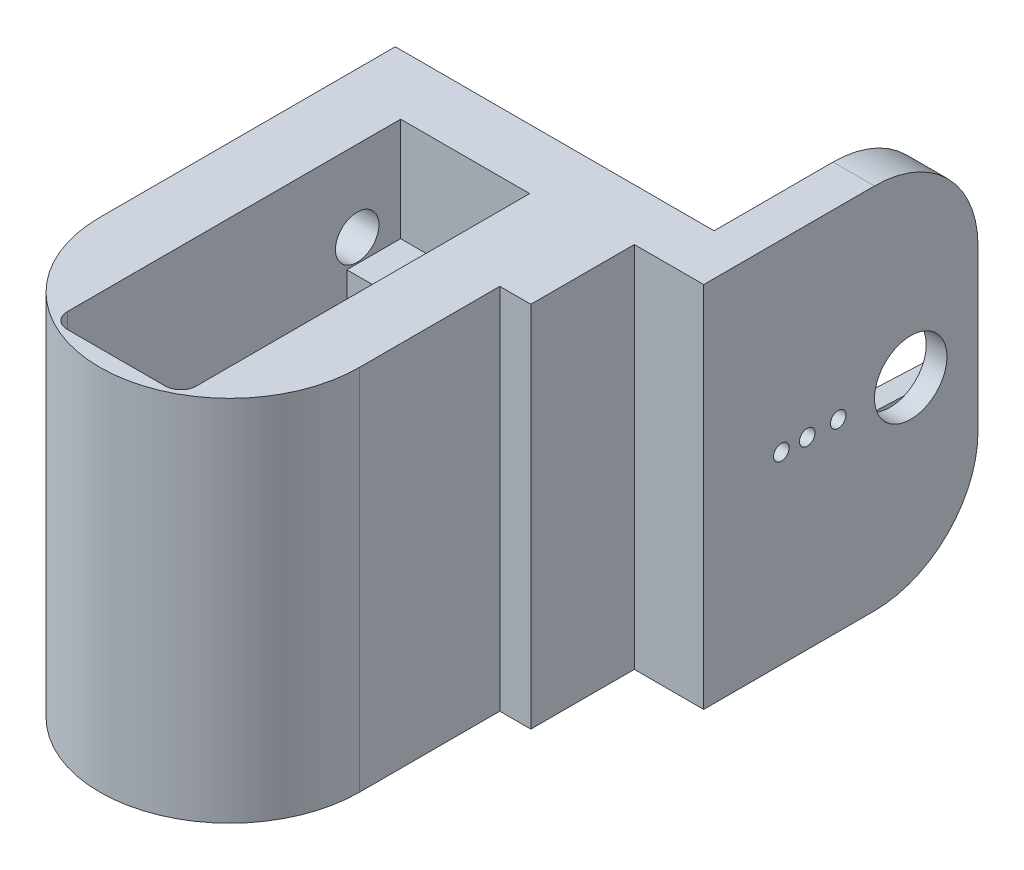
from build123d import *

# Parameters (mm, degrees)
SKETCH4_W                = 12.46
SKETCH4_H                = 17.25
BOSS_EXTRUDE3_DEPTH      = 6
SKETCH8_R                = 12.546781182
SKETCH8_R_2              = 11.15
BOSS_EXTRUDE6_DEPTH      = 8.3
BOSS_EXTRUDE6_DEPTH_BACK = 17.25
BOSS_EXTRUDE4_DEPTH      = 17.25
SKETCH6_R                = 0.75
CUT_EXTRUDE1_DEPTH       = 5
CHAMFER1_SIZE            = 0.5
CHAMFER1_SIZE2           = 0.866025404
SKETCH10_W               = 12.46
SKETCH10_H               = 23.7
CUT_EXTRUDE3_DEPTH       = 17.25
BOSS_EXTRUDE7_DEPTH      = 8.3
BOSS_EXTRUDE9_DEPTH      = 10
SKETCH20_R               = 11.15
SKETCH20_R_2             = 7.15
BOSS_EXTRUDE11_DEPTH     = 8.3
SKETCH21_R               = 10.15
SKETCH21_R_2             = 7.15
CUT_EXTRUDE7_DEPTH       = 1.3
SKETCH11_W               = 10
SKETCH11_H               = 2
CUT_EXTRUDE4_DEPTH       = 23.7
CUT_EXTRUDE8_REACH       = 37.55
SKETCH25_W               = 12.46
SKETCH25_H               = 6
BOSS_EXTRUDE10_DEPTH     = 35.55
SKETCH18_W               = 21.5
SKETCH18_H               = 11.438292938
CUT_EXTRUDE5_DEPTH       = 2
SKETCH19_R               = 3.5
CUT_EXTRUDE6_DEPTH       = 43.5
CUT_EXTRUDE6_DEPTH_BACK  = 3
FILLET1_R                = 10
SKETCH22_R               = 6.5
BOSS_EXTRUDE12_DEPTH     = 5
SKETCH23_R               = 5.85
BOSS_EXTRUDE13_DEPTH     = 5
FILLET2_R                = 1
BOSS_EXTRUDE14_DEPTH     = 2
CUT_EXTRUDE9_REACH       = 46.5
SKETCH27_R               = 0.75
CUT_EXTRUDE10_DEPTH      = 36.55
SKETCH29_R               = 2.1
SKETCH29_R_2             = 3.2
CUT_EXTRUDE11_DEPTH      = 7
FILLET3_R                = 1
SKETCH31_W               = 10
SKETCH31_H               = 35.55
BOSS_EXTRUDE15_DEPTH     = 3


with BuildPart() as part:
    # Sketch4 → Boss-Extrude3 (new body)
    with BuildSketch(Plane.XY):
        with Locations((0, -1.35)):
            Rectangle(SKETCH4_W, SKETCH4_H)
    extrude(amount=BOSS_EXTRUDE3_DEPTH)



with BuildPart() as body_2:
    # Sketch8 → Boss-Extrude6 (new body, two sides)
    with BuildSketch(Plane(origin=(0, -9.975, 0), x_dir=(-1, 0, 0), z_dir=(0, -1, 0))) as boss_extrude6_sk:
        with Locations((0, -23.55)):
            Circle(SKETCH8_R)
        with Locations((0, -23.55)):
            Circle(SKETCH8_R_2, mode=Mode.SUBTRACT)
    extrude(amount=BOSS_EXTRUDE6_DEPTH)
    extrude(boss_extrude6_sk.sketch, amount=-BOSS_EXTRUDE6_DEPTH_BACK)


with BuildPart() as part_1:
    add(part.part)

    add(body_2.part)  # Boss-Extrude4 merges body 2
    # Sketch5 → Boss-Extrude4 (add)
    with BuildSketch(Plane(origin=(0, 7.275, 0), x_dir=(1, 0, 0), z_dir=(0, 1, 0))):
        with BuildLine():
            Line((12.546781182, -23.55), (12.546781182, 0))
            Line((12.546781182, 0), (6.23, 0))
            Line((6.23, 0), (6.23, -29.7))
            Line((6.23, -29.7), (-6.23, -29.7))
            Line((-6.23, -29.7), (-6.23, 0))
            Line((-6.23, 0), (-12.546781182, 0))
            Line((-12.546781182, 0), (-12.546781182, -23.55))
            ThreePointArc((-12.546781182, -23.55), (0, -36.096781182), (12.546781182, -23.55))
        make_face()
    extrude(amount=-BOSS_EXTRUDE4_DEPTH)

    # Sketch6 → Cut-Extrude1 (cut)
    with BuildSketch(Plane(origin=(0, 7.275, 0), x_dir=(1, 0, 0), z_dir=(0, 1, 0))):
        with Locations((0, -3.6)):
            Circle(SKETCH6_R)
        with Locations((0, -32.1)):
            Circle(SKETCH6_R)
    extrude(amount=-CUT_EXTRUDE1_DEPTH, mode=Mode.SUBTRACT)

    # Chamfer1
    chamfer1_edges = [part_1.edges().sort_by_distance(p)[0] for p in [
        (-0.75, 7.275, 3.6),
        (-0.75, 7.275, 32.1),
    ]]
    chamfer1_side = [part_1.faces().sort_by_distance(p)[0] for p in [
        (0, 7.275, 35.657160381),
    ]]
    chamfer(chamfer1_edges, length=CHAMFER1_SIZE, length2=CHAMFER1_SIZE2, reference=chamfer1_side[0])

    # Sketch10 → Cut-Extrude3 (cut)
    with BuildSketch(Plane(origin=(0, 7.275, 0), x_dir=(1, 0, 0), z_dir=(0, 1, 0))):
        with Locations((0, -17.85)):
            Rectangle(SKETCH10_W, SKETCH10_H)
    extrude(amount=-CUT_EXTRUDE3_DEPTH, mode=Mode.SUBTRACT)

    # Sketch13 → Boss-Extrude7 (add)
    with BuildSketch(Plane.XZ.offset(18.275)):
        with BuildLine():
            Line((-12.546781182, 23.55), (-12.546781182, 0))
            Line((-12.546781182, 0), (12.546781182, 0))
            Line((12.546781182, 0), (12.546781182, 23.55))
            ThreePointArc((12.546781182, 23.55), (0, 11.003218818), (-12.546781182, 23.55))
        make_face()
    extrude(amount=-BOSS_EXTRUDE7_DEPTH)

    # Sketch15 → Boss-Extrude9 (add)
    with BuildSketch(Plane(origin=(0, 7.275, 0), x_dir=(1, 0, 0), z_dir=(0, 1, 0))):
        with BuildLine():
            Line((-12.546781182, 0), (12.546781182, 0))
            Line((12.546781182, 0), (12.546781182, -23.55))
            ThreePointArc((12.546781182, -23.55), (0, -36.096781182), (-12.546781182, -23.55))
            Line((-12.546781182, -23.55), (-12.546781182, 0))
        make_face()
        with BuildLine():
            Line((-6.23, -0.8), (6.23, -0.8))
            Line((6.23, -0.8), (6.23, -33))
            ThreePointArc((6.23, -33), (5.790660172, -34.060660172), (4.73, -34.5))
            Line((4.73, -34.5), (-4.73, -34.5))
            ThreePointArc((-4.73, -34.5), (-5.790660172, -34.060660172), (-6.23, -33))
            Line((-6.23, -33), (-6.23, -0.8))
        make_face(mode=Mode.SUBTRACT)
    extrude(amount=BOSS_EXTRUDE9_DEPTH)

    # Sketch20 → Boss-Extrude11 (add)
    with BuildSketch(Plane.XZ.offset(18.275)):
        with Locations((0, 23.55)):
            Circle(SKETCH20_R)
        with Locations((0, 23.55)):
            Circle(SKETCH20_R_2, mode=Mode.SUBTRACT)
    extrude(amount=-BOSS_EXTRUDE11_DEPTH)

    # Sketch21 → Cut-Extrude7 (cut)
    with BuildSketch(Plane.XZ.offset(18.275)):
        with Locations((0, 23.55)):
            Circle(SKETCH21_R)
        with Locations((0, 23.55)):
            Circle(SKETCH21_R_2, mode=Mode.SUBTRACT)
    extrude(amount=-CUT_EXTRUDE7_DEPTH, mode=Mode.SUBTRACT)

    # Sketch11 → Cut-Extrude4 (cut)
    with BuildSketch(Plane.XY.offset(29.7)):
        with Locations((0, -10.975)):
            Rectangle(SKETCH11_W, SKETCH11_H)
    extrude(amount=-CUT_EXTRUDE4_DEPTH, mode=Mode.SUBTRACT)

    # Sketch25 → Cut-Extrude8 (cut, up to next)
    with BuildSketch(Plane.XZ.offset(18.275), mode=Mode.PRIVATE) as cut_extrude8_sk1:
        with Locations((0, 9)):
            Rectangle(SKETCH25_W, SKETCH25_H)
    cut_extrude8_tool1 = extrude(cut_extrude8_sk1.sketch, amount=-CUT_EXTRUDE8_REACH, mode=Mode.PRIVATE) & part_1.part
    add(cut_extrude8_tool1.solids().sort_by_distance((0, -18.275, 9))[0], mode=Mode.SUBTRACT)

    # Sketch17 → Boss-Extrude10 (add)
    with BuildSketch(Plane(origin=(0, 17.275, 0), x_dir=(1, 0, 0), z_dir=(0, 1, 0))):
        Polygon((22.25, 26.5), (22.25, 0), (-22.25, 0), (-22.25, 26.5), (-18.25, 26.5), (-18.25, 5), (18.25, 5), (18.25, 26.5), align=None)
    extrude(amount=-BOSS_EXTRUDE10_DEPTH)

    # Sketch18 → Cut-Extrude5 (cut)
    with BuildSketch(Plane.ZY.offset(-18.25)):
        with Locations((-15.75, -0.5)):
            Rectangle(SKETCH18_W, SKETCH18_H)
    extrude(amount=-CUT_EXTRUDE5_DEPTH, mode=Mode.SUBTRACT)

    # Sketch19 → Cut-Extrude6 (cut, two sides)
    with BuildSketch(Plane.ZY.offset(-20.25)) as cut_extrude6_sk:
        with Locations((-20, -0.5)):
            Circle(SKETCH19_R)
    extrude(amount=CUT_EXTRUDE6_DEPTH, mode=Mode.SUBTRACT)
    extrude(cut_extrude6_sk.sketch, amount=-CUT_EXTRUDE6_DEPTH_BACK, mode=Mode.SUBTRACT)

    # Fillet1
    fillet1_edges = [part_1.edges().sort_by_distance(p)[0] for p in [
        (20.25, 17.275, -26.5),
        (-20.25, 17.275, -26.5),
        (-20.25, -18.275, -26.5),
        (20.25, -18.275, -26.5),
    ]]
    fillet(fillet1_edges, radius=FILLET1_R)

    # Sketch22 → Boss-Extrude12 (add)
    with BuildSketch(Plane.ZY.offset(22.25)):
        with Locations((-20, -0.5)):
            Circle(SKETCH22_R)
    extrude(amount=-BOSS_EXTRUDE12_DEPTH)

    # Sketch23 → Boss-Extrude13 (add)
    with BuildSketch(Plane(origin=(-17.25, 0, 0), x_dir=(0, 0, -1), z_dir=(1, 0, 0))):
        with Locations((20, -0.5)):
            Circle(SKETCH23_R)
    extrude(amount=BOSS_EXTRUDE13_DEPTH)

    # Fillet2
    fillet2_edges = [part_1.edges().sort_by_distance(p)[0] for p in [
        (-12.25, -0.5, -14.15),
    ]]
    fillet(fillet2_edges, radius=FILLET2_R)

    # Sketch26 → Boss-Extrude14 (add)
    with BuildSketch(Plane.ZY.offset(-20.25)):
        Polygon((-5, 2), (-20, 2.6585), (-26.5, 2.94385), (-26.5, 5.219146469), (-5, 5.219146469), align=None)
        Polygon((-20, -3.6585), (-5, -3), (-5, -6.219146469), (-26.5, -6.219146469), (-26.5, -3.94385), align=None)
    extrude(amount=BOSS_EXTRUDE14_DEPTH)

    # Sketch27 → Cut-Extrude9 (cut, up to next)
    with BuildSketch(Plane(origin=(22.25, 0, 0), x_dir=(0, 0, -1), z_dir=(1, 0, 0)), mode=Mode.PRIVATE) as cut_extrude9_sk1:
        with Locations((10, -0.5)):
            Circle(SKETCH27_R)
    cut_extrude9_tool1 = extrude(cut_extrude9_sk1.sketch, amount=-CUT_EXTRUDE9_REACH, mode=Mode.PRIVATE) & part_1.part
    add(cut_extrude9_tool1.solids().sort_by_distance((22.25, -0.5, -10))[0], mode=Mode.SUBTRACT)
    # Sketch27 → Cut-Extrude9 (cut, up to next)
    with BuildSketch(Plane(origin=(22.25, 0, 0), x_dir=(0, 0, -1), z_dir=(1, 0, 0)), mode=Mode.PRIVATE) as cut_extrude9_sk2:
        with Locations((7.5, -0.5)):
            Circle(SKETCH27_R)
    cut_extrude9_tool2 = extrude(cut_extrude9_sk2.sketch, amount=-CUT_EXTRUDE9_REACH, mode=Mode.PRIVATE) & part_1.part
    add(cut_extrude9_tool2.solids().sort_by_distance((22.25, -0.5, -7.5))[0], mode=Mode.SUBTRACT)
    # Sketch27 → Cut-Extrude9 (cut, up to next)
    with BuildSketch(Plane(origin=(22.25, 0, 0), x_dir=(0, 0, -1), z_dir=(1, 0, 0)), mode=Mode.PRIVATE) as cut_extrude9_sk3:
        with Locations((13, -0.5)):
            Circle(SKETCH27_R)
    cut_extrude9_tool3 = extrude(cut_extrude9_sk3.sketch, amount=-CUT_EXTRUDE9_REACH, mode=Mode.PRIVATE) & part_1.part
    add(cut_extrude9_tool3.solids().sort_by_distance((22.25, -0.5, -13))[0], mode=Mode.SUBTRACT)

    # Sketch28 → Cut-Extrude10 (cut, through all)
    with BuildSketch(Plane.XZ.offset(18.275)):
        Polygon((-12.546781182, 23.55), (-12.546781182, -11.553408701), (-1.720894485, -11.553408701), (-1.720894485, -30.302101254), (-26.809724616, -30.302101254), (-26.809724616, 23.55), align=None)
    extrude(amount=-CUT_EXTRUDE10_DEPTH, mode=Mode.SUBTRACT)

    # Sketch29 → Cut-Extrude11 (cut)
    with BuildSketch(Plane.ZY.offset(12.546781182)):
        with Locations((5, 9.5)):
            Circle(SKETCH29_R)
        with Locations((5, -10.5)):
            Circle(SKETCH29_R)
        with Locations((5, -0.5)):
            Circle(SKETCH29_R_2)
    extrude(amount=-CUT_EXTRUDE11_DEPTH, mode=Mode.SUBTRACT)

    # Fillet3
    fillet3_edges = [part_1.edges().sort_by_distance(p)[0] for p in [
        (-12.546781182, 9.5, 2.9),
        (-12.546781182, -10.5, 2.9),
    ]]
    fillet(fillet3_edges, radius=FILLET3_R)

    # Sketch31 → Boss-Extrude15 (add)
    with BuildSketch(Plane(origin=(12.546781182, 0, 0), x_dir=(0, 0, -1), z_dir=(1, 0, 0))):
        with Locations((-5, -0.5)):
            Rectangle(SKETCH31_W, SKETCH31_H)
    extrude(amount=BOSS_EXTRUDE15_DEPTH)


solid = part_1.part
